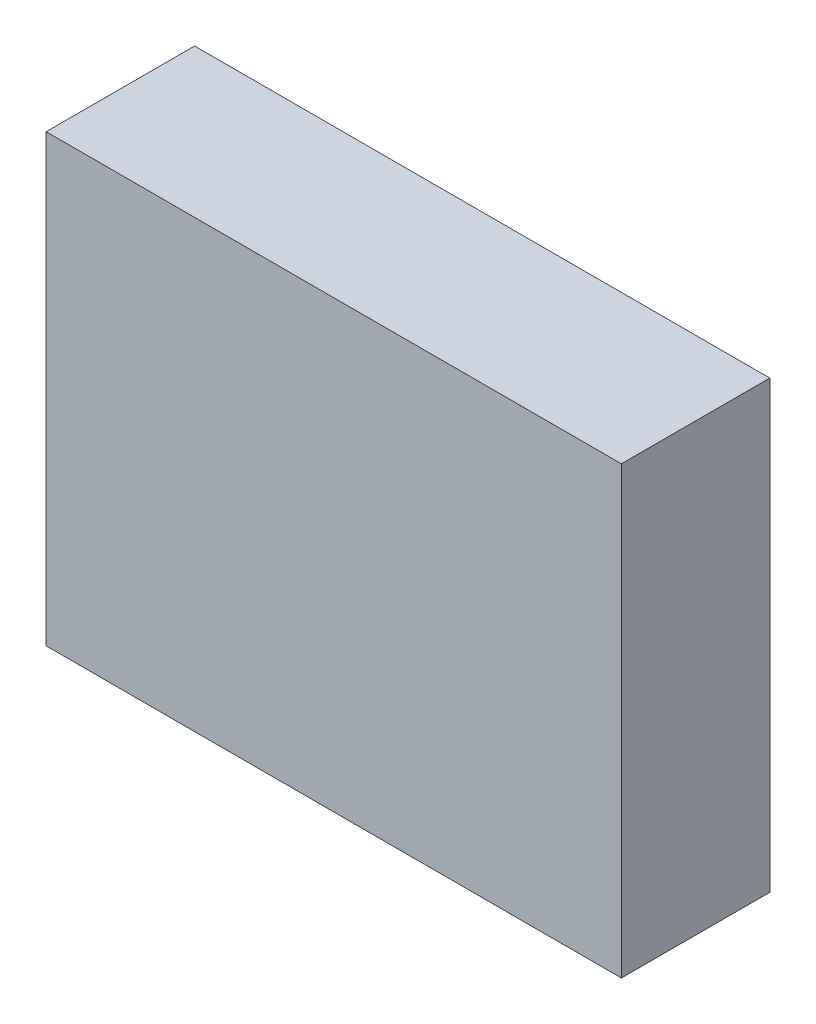
from build123d import *

# Parameters (mm, degrees)
SKETCH1_W           = 196.85
SKETCH1_H           = 152.4
BOSS_EXTRUDE1_DEPTH = 50.8


with BuildPart() as part:
    # Sketch1 → Boss-Extrude1 (new body)
    with BuildSketch(Plane.XY):
        Rectangle(SKETCH1_W, SKETCH1_H)
    extrude(amount=BOSS_EXTRUDE1_DEPTH)


solid = part.part
